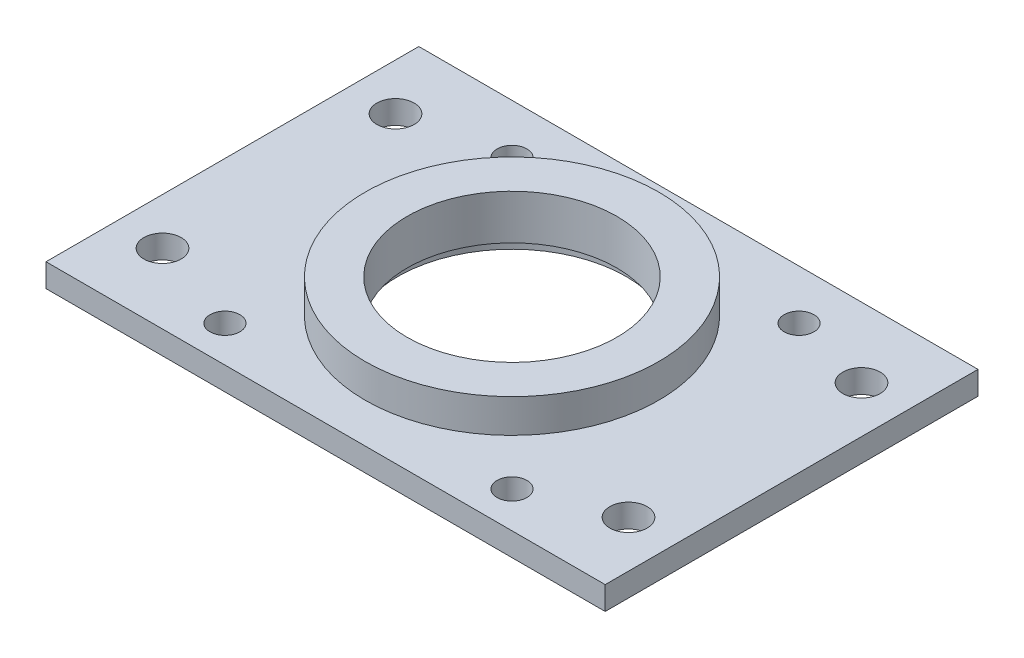
from build123d import *

# Parameters (mm, degrees)
SKETCH1_R           = 20.0025
SKETCH1_R_2         = 14.2875
BOSS_EXTRUDE1_DEPTH = 4.572
SKETCH2_W           = 76.2
SKETCH2_H           = 50.8
SKETCH2_R           = 14.2875
BOSS_EXTRUDE2_DEPTH = 3.175
SKETCH3_R           = 15.5575
CUT_EXTRUDE1_DEPTH  = 1.651
SKETCH5_R           = 2.032
SKETCH5_R_2         = 2.54
CUT_EXTRUDE2_DEPTH  = 4.175


with BuildPart() as part:
    # Sketch1 → Boss-Extrude1 (new body)
    with BuildSketch(Plane(origin=(0, 0, 0), x_dir=(1, 0, 0), z_dir=(0, 1, 0))):
        Circle(SKETCH1_R)
        Circle(SKETCH1_R_2, mode=Mode.SUBTRACT)
    extrude(amount=BOSS_EXTRUDE1_DEPTH)

    # Sketch2 → Boss-Extrude2 (add)
    with BuildSketch(Plane.XZ):
        Rectangle(SKETCH2_W, SKETCH2_H)
        Circle(SKETCH2_R, mode=Mode.SUBTRACT)
    extrude(amount=BOSS_EXTRUDE2_DEPTH)

    # Sketch3 → Cut-Extrude1 (cut)
    with BuildSketch(Plane.XZ.offset(3.175)):
        Circle(SKETCH3_R)
    extrude(amount=-CUT_EXTRUDE1_DEPTH, mode=Mode.SUBTRACT)

    # Sketch5 → Cut-Extrude2 (cut, through all)
    with BuildSketch(Plane(origin=(0, 0, 0), x_dir=(1, 0, 0), z_dir=(0, 1, 0))):
        with Locations((-18.64995, 18.64995)):
            Circle(SKETCH5_R)
        with Locations((20.46605, 18.64995)):
            Circle(SKETCH5_R)
        with Locations((-18.64995, -20.46605)):
            Circle(SKETCH5_R)
        with Locations((20.46605, -20.46605)):
            Circle(SKETCH5_R)
        with Locations((-31.75, 15.875)):
            Circle(SKETCH5_R_2)
        with Locations((31.75, 15.875)):
            Circle(SKETCH5_R_2)
        with Locations((31.75, -15.875)):
            Circle(SKETCH5_R_2)
        with Locations((-31.75, -15.875)):
            Circle(SKETCH5_R_2)
    extrude(amount=-CUT_EXTRUDE2_DEPTH, mode=Mode.SUBTRACT)


solid = part.part
